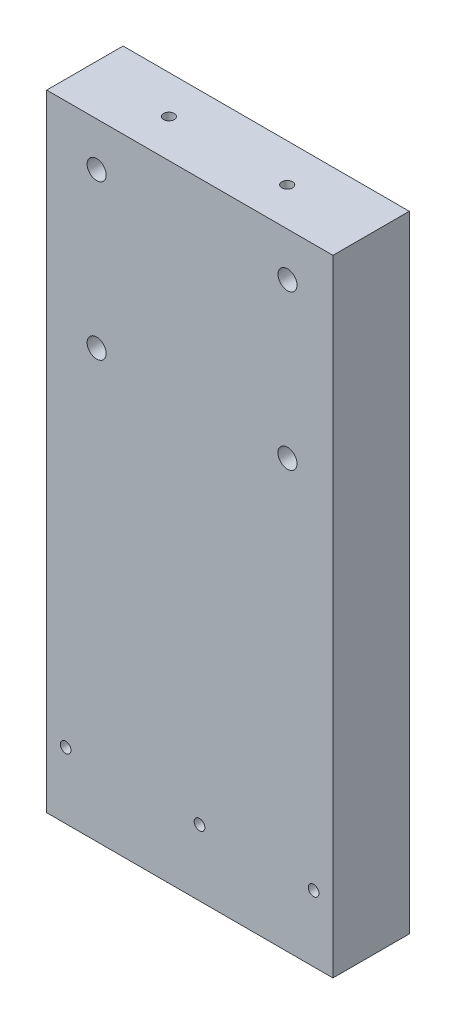
from build123d import *

# Parameters (mm, degrees)
SKETCH1_W           = 75
SKETCH1_H           = 164
SKETCH1_R           = 1.4
SKETCH1_R_2         = 2.5
BOSS_EXTRUDE1_DEPTH = 20
SKETCH2_R           = 1.4
CUT_EXTRUDE1_DEPTH  = 165


with BuildPart() as part:
    # Sketch1 → Boss-Extrude1 (new body)
    with BuildSketch(Plane.XY):
        Rectangle(SKETCH1_W, SKETCH1_H)
        with Locations((-32.5324139, -64.662730375)):
            Circle(SKETCH1_R, mode=Mode.SUBTRACT)
        with Locations((32.436706201, -64.662730375)):
            Circle(SKETCH1_R, mode=Mode.SUBTRACT)
        with Locations((2.542, -64.662730375)):
            Circle(SKETCH1_R, mode=Mode.SUBTRACT)
        with Locations((25.583768895, 30)):
            Circle(SKETCH1_R_2, mode=Mode.SUBTRACT)
        with Locations((-24.416231105, 70.5)):
            Circle(SKETCH1_R_2, mode=Mode.SUBTRACT)
        with Locations((25.583768895, 70.5)):
            Circle(SKETCH1_R_2, mode=Mode.SUBTRACT)
        with Locations((-24.416231105, 30)):
            Circle(SKETCH1_R_2, mode=Mode.SUBTRACT)
    extrude(amount=BOSS_EXTRUDE1_DEPTH)

    # Sketch2 → Cut-Extrude1 (cut, through all)
    with BuildSketch(Plane(origin=(0, 82, 0), x_dir=(1, 0, 0), z_dir=(0, 1, 0))):
        with Locations((15.509889123, -9.995038215)):
            Circle(SKETCH2_R)
        with Locations((-15.490110877, -9.995038215)):
            Circle(SKETCH2_R)
    extrude(amount=-CUT_EXTRUDE1_DEPTH, mode=Mode.SUBTRACT)


solid = part.part
